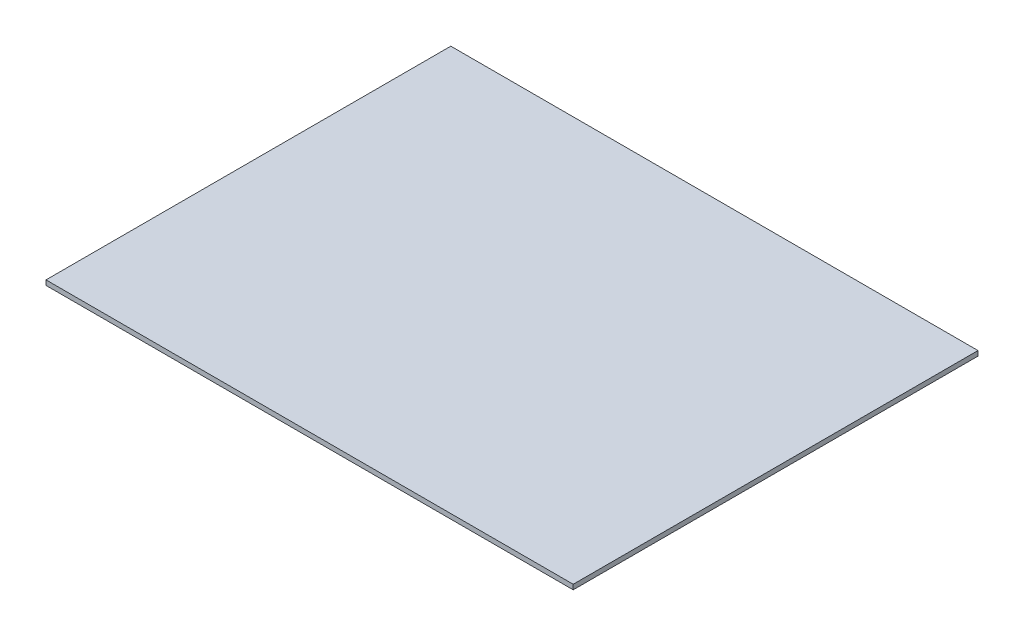
from build123d import *

# Parameters (mm, degrees)
SKETCH_1_W      = 435
SKETCH_1_H      = 334
EXTRUDE_1_DEPTH = 4


with BuildPart() as part:
    # Эскиз1 → Бобышка-Вытянуть1 (new body)
    with BuildSketch(Plane(origin=(0, 0, 0), x_dir=(1, 0, 0), z_dir=(0, 1, 0))):
        Rectangle(SKETCH_1_W, SKETCH_1_H)
    extrude(amount=EXTRUDE_1_DEPTH)


solid = part.part
